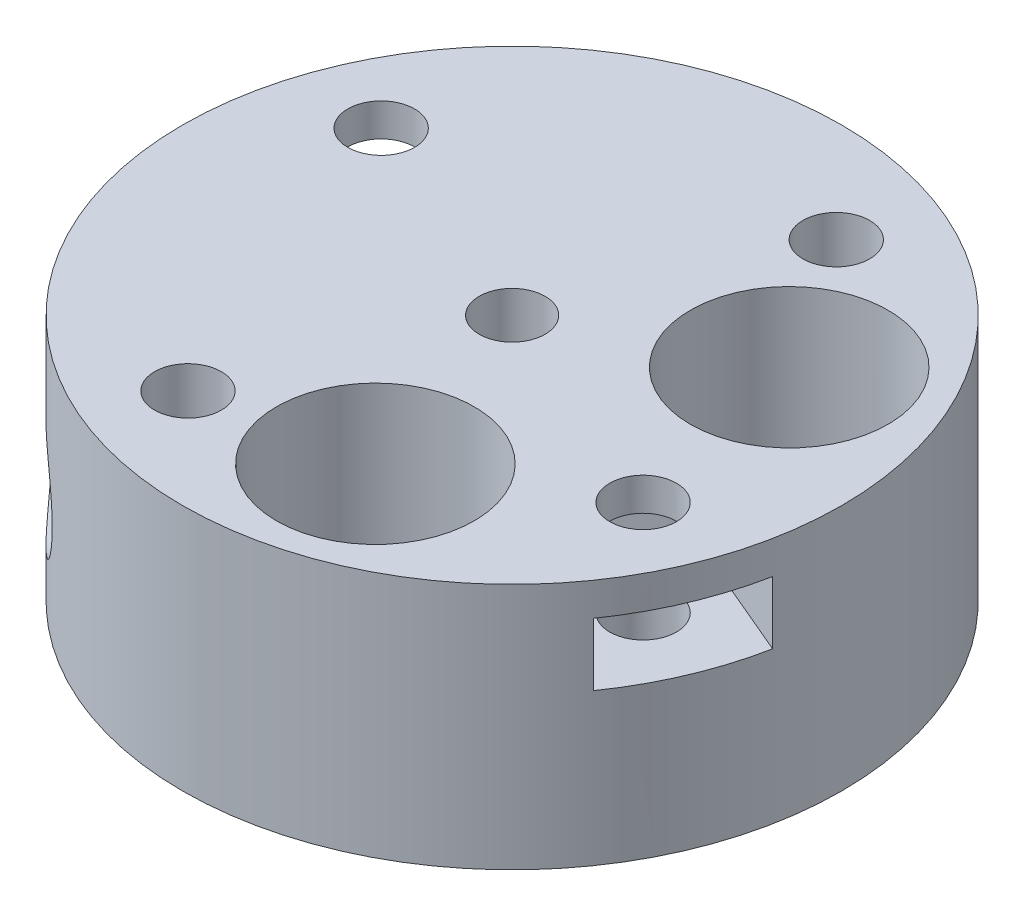
from build123d import *

# Parameters (mm, degrees)
SKETCH1_R               = 20
BOSS_EXTRUDE1_DEPTH     = 7.5
SKETCH4_R               = 5.125
CUT_EXTRUDE2_DEPTH      = 12.15
SKETCH5_R               = 2
CUT_EXTRUDE3_DEPTH      = 1
CUT_EXTRUDE3_DEPTH_BACK = 16
SKETCH15_W              = 8.1
SKETCH15_H              = 1.984438744
BOSS_EXTRUDE3_DEPTH     = 12.15
SKETCH2_R               = 2.025
CUT_EXTRUDE1_DEPTH      = 16
CIRPATTERN1_COUNT       = 4
SKETCH6_R               = 1.525
CUT_EXTRUDE4_DEPTH      = 21
CUT_EXTRUDE5_START      = -20
SKETCH7_R               = 3.25
CUT_EXTRUDE5_DEPTH      = 8
CUT_EXTRUDE11_START     = -6.5
CUT_EXTRUDE11_DEPTH     = 2.9
CIRPATTERN2_COUNT       = 2
CIRPATTERN2_ANGLE       = 135
CUT_EXTRUDE7_START      = 5.5
CUT_EXTRUDE7_DEPTH      = 3.8
CIRPATTERN3_COUNT       = 2
CUT_EXTRUDE12_START     = -16.0000001
SKETCH10_R              = 6
CUT_EXTRUDE12_DEPTH     = 17.0000002
CIRPATTERN4_COUNT       = 2
CIRPATTERN4_ANGLE       = 100


with BuildPart() as part:
    # Sketch1 → Boss-Extrude1 (new body, symmetric)
    with BuildSketch(Plane(origin=(0, 0, 0), x_dir=(1, 0, 0), z_dir=(0, 1, 0))):
        Circle(SKETCH1_R)
    extrude(amount=BOSS_EXTRUDE1_DEPTH, both=True)

    # Sketch4 → Cut-Extrude2 (cut)
    with BuildSketch(Plane.XZ.offset(7.5)):
        Circle(SKETCH4_R)
    extrude(amount=-CUT_EXTRUDE2_DEPTH, mode=Mode.SUBTRACT)

    # Sketch5 → Cut-Extrude3 (cut, two sides)
    with BuildSketch(Plane(origin=(0, 7.5, 0), x_dir=(1, 0, 0), z_dir=(0, 1, 0))) as cut_extrude3_sk:
        Circle(SKETCH5_R)
    extrude(amount=CUT_EXTRUDE3_DEPTH, mode=Mode.SUBTRACT)
    extrude(cut_extrude3_sk.sketch, amount=-CUT_EXTRUDE3_DEPTH_BACK, mode=Mode.SUBTRACT)

    # Sketch15 → Boss-Extrude3 (add)
    with BuildSketch(Plane.XZ.offset(7.5)):
        with Locations((0, -4.132780628)):
            Rectangle(SKETCH15_W, SKETCH15_H)
    extrude(amount=-BOSS_EXTRUDE3_DEPTH)

    # Sketch2 → Cut-Extrude1 (cut, through all)
    with BuildSketch(Plane(origin=(0, 7.5, 0), x_dir=(1, 0, 0), z_dir=(0, 1, 0))):
        with Locations((-13.807572802, 5.860966927)):
            Circle(SKETCH2_R)
    cut_extrude1 = extrude(amount=-CUT_EXTRUDE1_DEPTH, mode=Mode.SUBTRACT)

    # CirPattern1: Cut-Extrude1 ×4 about axis
    cirpattern1_axis = Axis((0, 0, 0), (0, 1, 0))
    for i in range(1, CIRPATTERN1_COUNT):
        add(cut_extrude1.rotate(cirpattern1_axis, i * 360 / CIRPATTERN1_COUNT), mode=Mode.SUBTRACT)

    # Sketch6 → Cut-Extrude4 (cut, through all)
    with BuildSketch(Plane.XY):
        with Locations((0, -1.35)):
            Circle(SKETCH6_R)
    cut_extrude4 = extrude(amount=-CUT_EXTRUDE4_DEPTH, mode=Mode.SUBTRACT)

    # Sketch7 → Cut-Extrude5 (cut)
    with BuildSketch(Plane.XY.offset(CUT_EXTRUDE5_START)):
        with Locations((0, -1.35)):
            Circle(SKETCH7_R)
    cut_extrude5 = extrude(amount=CUT_EXTRUDE5_DEPTH, mode=Mode.SUBTRACT)

    # Sketch9 → Cut-Extrude11 (cut)
    with BuildSketch(Plane.XY.offset(CUT_EXTRUDE11_START)):
        Polygon((3.15, -3.168653348), (3.15, 0.468653348), (0, 2.287306696), (-3.15, 0.468653348), (-3.15, -3.168653348), (-3.15, -7.685074736), (3.15, -7.685074736), align=None)
    cut_extrude11 = extrude(amount=-CUT_EXTRUDE11_DEPTH, mode=Mode.SUBTRACT)

    # CirPattern2: Cut-Extrude4, Cut-Extrude5, Cut-Extrude11 ×2 about axis
    cirpattern2_axis = Axis((0, 0, 0), (0, 1, 0))
    for i in range(1, CIRPATTERN2_COUNT):
        add(cut_extrude4.rotate(cirpattern2_axis, i * CIRPATTERN2_ANGLE / (CIRPATTERN2_COUNT - 1)), mode=Mode.SUBTRACT)
        add(cut_extrude5.rotate(cirpattern2_axis, i * CIRPATTERN2_ANGLE / (CIRPATTERN2_COUNT - 1)), mode=Mode.SUBTRACT)
        add(cut_extrude11.rotate(cirpattern2_axis, i * CIRPATTERN2_ANGLE / (CIRPATTERN2_COUNT - 1)), mode=Mode.SUBTRACT)

    # Sketch8 → Cut-Extrude7 (cut)
    with BuildSketch(Plane(origin=(0, 0, 0), x_dir=(1, 0, 0), z_dir=(0, 1, 0)).offset(CUT_EXTRUDE7_START)):
        Polygon((-9.396506885, 3.988580533), (-9.98050566, 8.744868872), (-14.391571577, 10.617255266), (-19.569899143, 12.815324908), (-22.81296751, 5.175134625), (-17.634639943, 2.977064983), (-13.223574027, 1.104678588), align=None)
    cut_extrude7 = extrude(amount=-CUT_EXTRUDE7_DEPTH, mode=Mode.SUBTRACT)

    # CirPattern3: Cut-Extrude7 ×2 about axis
    cirpattern3_axis = Axis((0, 0, 0), (0, 1, 0))
    for i in range(1, CIRPATTERN3_COUNT):
        add(cut_extrude7.rotate(cirpattern3_axis, i * 360 / CIRPATTERN3_COUNT), mode=Mode.SUBTRACT)

    # Sketch10 → Cut-Extrude12 (cut)
    with BuildSketch(Plane(origin=(0, 7.5, 0), x_dir=(1, 0, 0), z_dir=(0, 1, 0)).offset(CUT_EXTRUDE12_START)):
        with Locations((3.654646309, -11.95380945)):
            Circle(SKETCH10_R)
    cut_extrude12 = extrude(amount=CUT_EXTRUDE12_DEPTH, mode=Mode.SUBTRACT)

    # CirPattern4: Cut-Extrude12 ×2 about axis
    cirpattern4_axis = Axis((0, 7.5, 0), (0, 1, 0))
    for i in range(1, CIRPATTERN4_COUNT):
        add(cut_extrude12.rotate(cirpattern4_axis, i * CIRPATTERN4_ANGLE / (CIRPATTERN4_COUNT - 1)), mode=Mode.SUBTRACT)


solid = part.part
